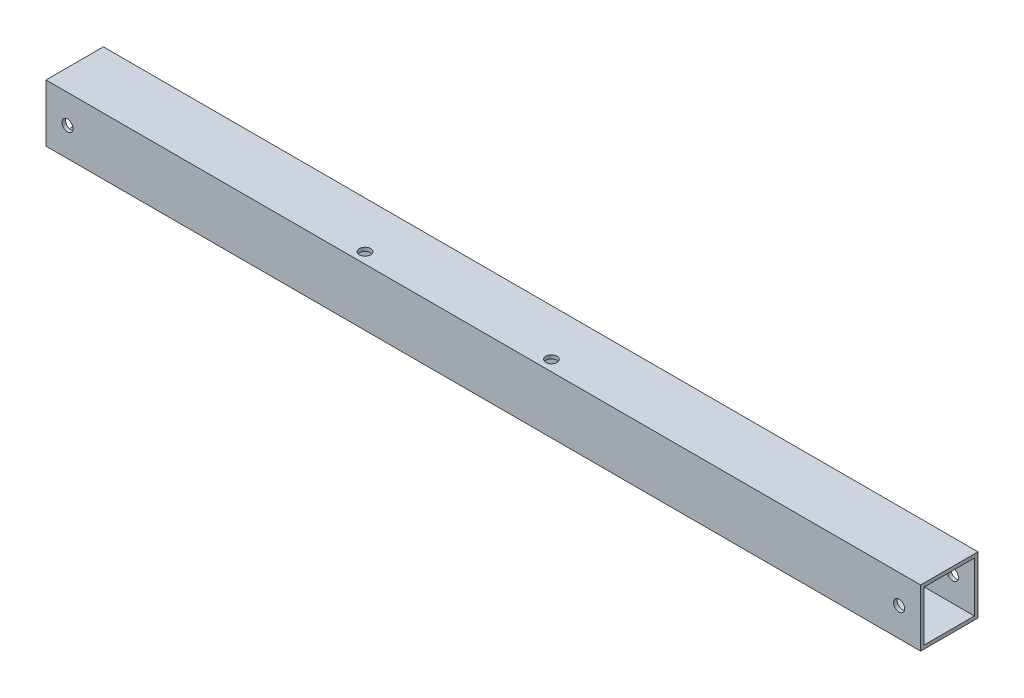
from build123d import *

# Parameters (mm, degrees)
SKETCH1_W                    = 25.4
SKETCH1_H                    = 25.4
SKETCH1_W_2                  = 22.225
SKETCH1_H_2                  = 22.225
EXTRUDE_THIN1_DEPTH          = 387.35
F_10_0_1935_DIAMETER_HOLE1_D = 4.9149
F_10_0_1935_DIAMETER_HOLE2_D = 4.9149


with BuildPart() as part:
    # Sketch1 → Extrude-Thin1 (new body)
    with BuildSketch(Plane(origin=(0, 0, 0), x_dir=(0, 0, -1), z_dir=(1, 0, 0))):
        Rectangle(SKETCH1_W, SKETCH1_H)
        Rectangle(SKETCH1_W_2, SKETCH1_H_2, mode=Mode.SUBTRACT)
    extrude(amount=EXTRUDE_THIN1_DEPTH)

    # #10 (0.1935) Diameter Hole1 (through all)
    with Locations(Plane.XY.offset(12.7)):
        with Locations((9.525, 0), (377.825, 0)):
            Hole(F_10_0_1935_DIAMETER_HOLE1_D / 2)

    # #10 (0.1935) Diameter Hole2 (through all)
    with Locations(Plane(origin=(0, 12.7, 0), x_dir=(1, 0, 0), z_dir=(0, 1, 0))):
        with Locations((136.525, -7.9375), (219.075, -7.9375)):
            Hole(F_10_0_1935_DIAMETER_HOLE2_D / 2)


solid = part.part
